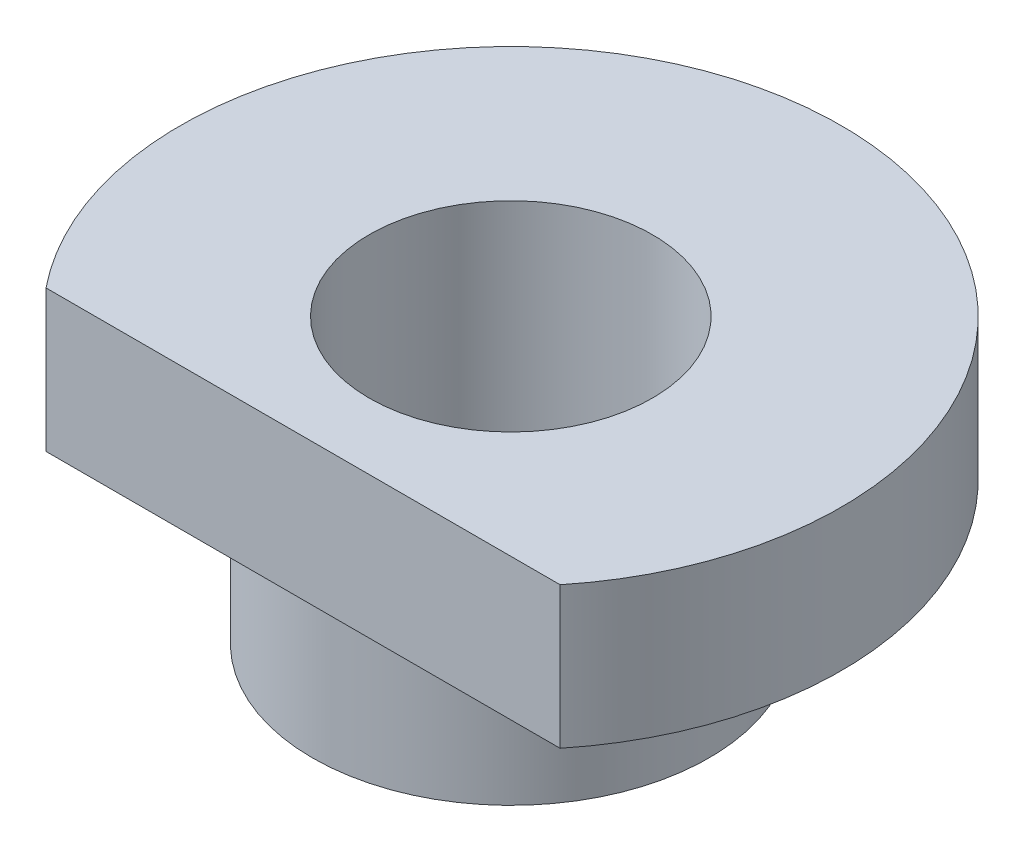
from build123d import *

# Parameters (mm, degrees)
ENL_V_START             = 2.2
ESQUISSE2_W             = 8.060370584
ESQUISSE2_H             = 3.607489546
ENL_V_MAT_EXTRU_1_DEPTH = 10


with BuildPart() as part:
    # Esquisse1 → Révolution1 (revolve)
    with BuildSketch(Plane.XY, mode=Mode.PRIVATE) as r_volution1_sk:
        Polygon((2.1, 0), (3.5, 0), (3.5, 1.5), (1.5, 1.5), (1.5, -1.5), (2.1, -1.5), align=None)
    revolve(r_volution1_sk.sketch.rotate(Axis((0, 0, 0), (0, -1, 0)), 90), axis=Axis((0, 0, 0), (0, -1, 0)))  # turned: the seam where the file's is

    # Esquisse2 → Enlèv. mat.-Extru.1 (cut)
    with BuildSketch(Plane.XY.offset(ENL_V_START)):
        Rectangle(ESQUISSE2_W, ESQUISSE2_H)
    extrude(amount=ENL_V_MAT_EXTRU_1_DEPTH, mode=Mode.SUBTRACT)


solid = part.part
